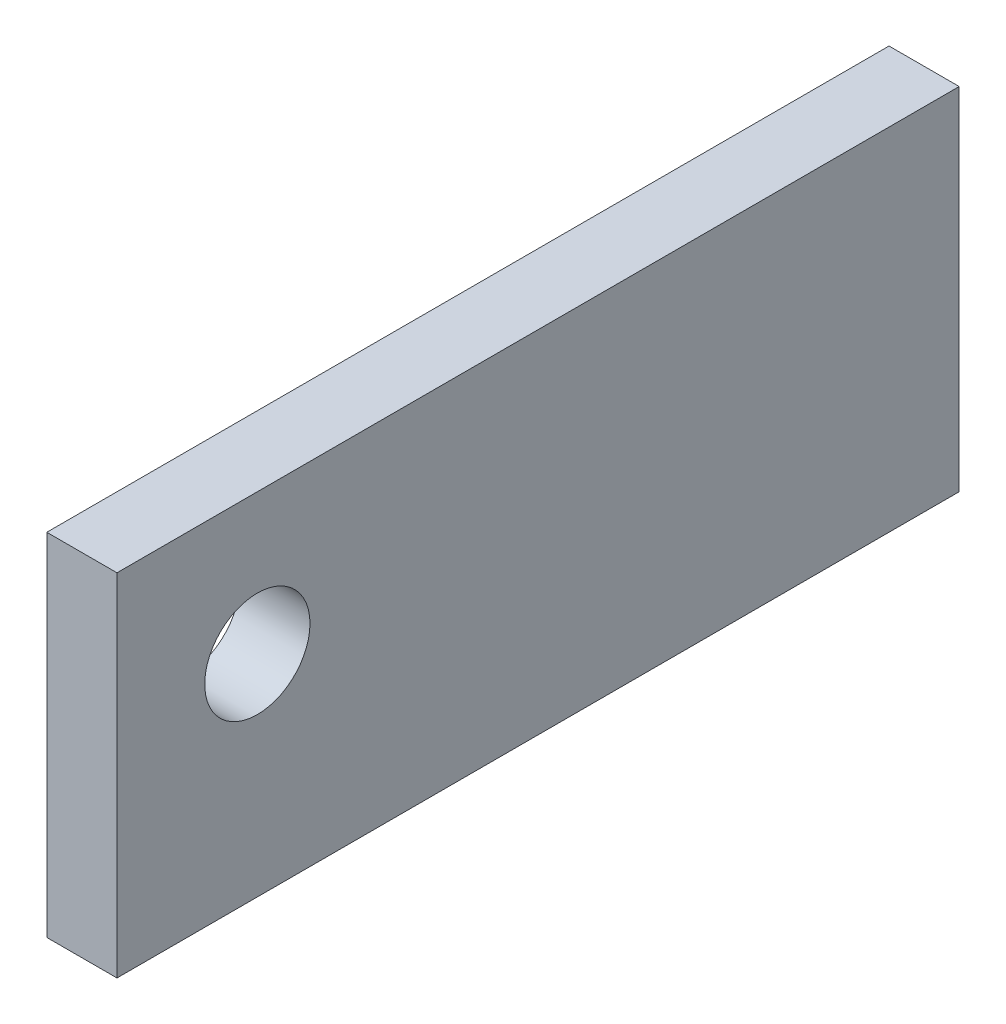
from build123d import *

# Parameters (mm, degrees)
SKETCH1_W           = 152.4
SKETCH1_H           = 63.5
BOSS_EXTRUDE1_DEPTH = 6.35
CUT_EXTRUDE1_REACH  = 14.7
SKETCH2_R           = 9.525


with BuildPart() as part:
    # Sketch1 → Boss-Extrude1 (new body, symmetric)
    with BuildSketch(Plane(origin=(0, 0, 0), x_dir=(0, 0, -1), z_dir=(1, 0, 0))):
        Rectangle(SKETCH1_W, SKETCH1_H)
    extrude(amount=BOSS_EXTRUDE1_DEPTH, both=True)

    # Sketch2 → Cut-Extrude1 (cut, up to next)
    with BuildSketch(Plane(origin=(6.35, 0, 0), x_dir=(0, 0, -1), z_dir=(1, 0, 0)), mode=Mode.PRIVATE) as cut_extrude1_sk1:
        with Locations((-50.8, 6.35)):
            Circle(SKETCH2_R)
    cut_extrude1_tool1 = extrude(cut_extrude1_sk1.sketch, amount=-CUT_EXTRUDE1_REACH, mode=Mode.PRIVATE) & part.part
    add(cut_extrude1_tool1.solids().sort_by_distance((6.35, 6.35, 50.8))[0], mode=Mode.SUBTRACT)


solid = part.part
